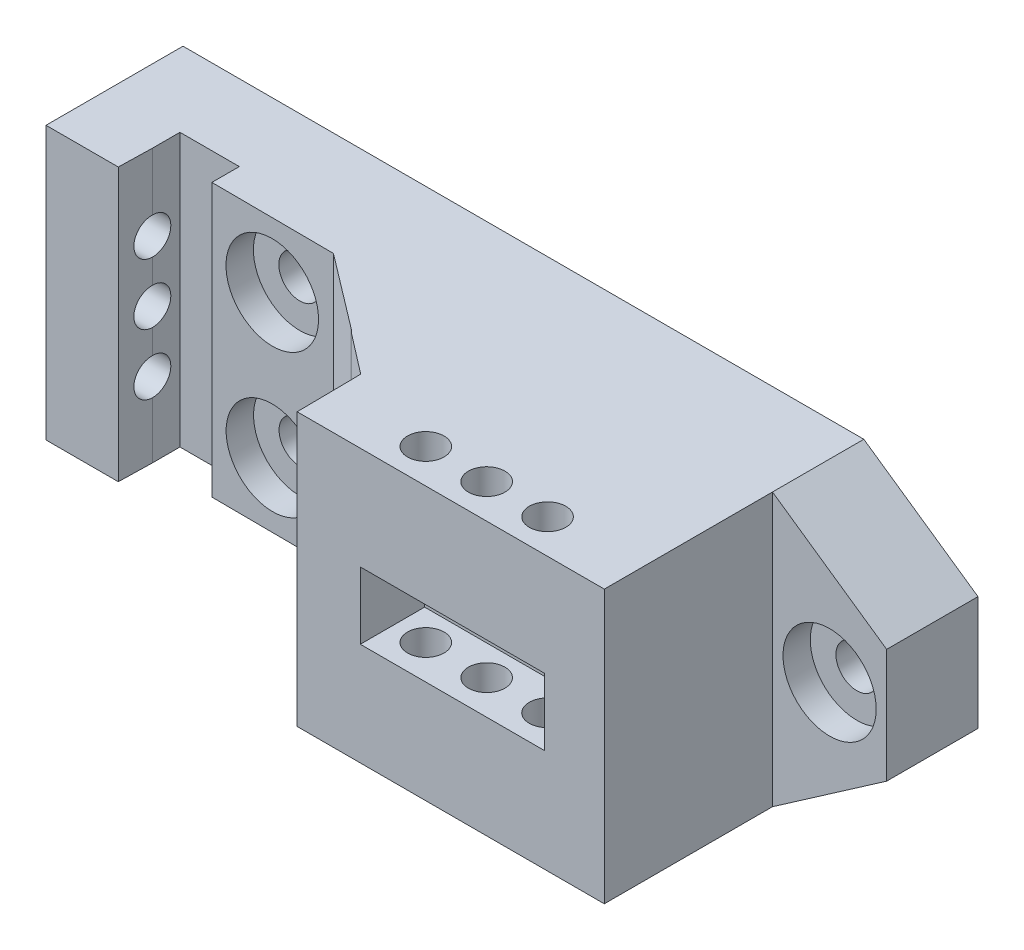
from build123d import *

# Parameters (mm, degrees)
SKETCH2_R                               = 2.4
BOSS_EXTRUDE1_DEPTH                     = 35.814
CUT_EXTRUDE1_DEPTH                      = 8.45076
CBORE_FOR_M5_HEX_HEAD_BOLT1_D           = 5.5
CBORE_FOR_M5_HEX_HEAD_BOLT1_CBORE_D     = 12.24
CBORE_FOR_M5_HEX_HEAD_BOLT1_CBORE_DEPTH = 3.58
BOSS_EXTRUDE2_DEPTH                     = 12
CBORE_FOR_M5_HEX_HEAD_BOLT2_D           = 5.5
CBORE_FOR_M5_HEX_HEAD_BOLT2_DEPTH       = 12
CBORE_FOR_M5_HEX_HEAD_BOLT2_CBORE_D     = 12.24
CBORE_FOR_M5_HEX_HEAD_BOLT2_CBORE_DEPTH = 3.58
CUT_EXTRUDE2_REACH                      = 106.459
SKETCH11_R                              = 2.4


with BuildPart() as part:
    # Sketch2 → Boss-Extrude1 (new body)
    with BuildSketch(Plane(origin=(0, 0, 0), x_dir=(1, 0, 0), z_dir=(0, 1, 0))):
        Polygon((79.858578644, 45.6), (79.858578644, 11.5), (39.5, 11.5), (39.4, 19.95075985), (34.265987805, 23.9), (33.603154542, 24.5), (23.866312437, 31.9), (7.8, 32), (7.8, 35.6), (0, 35.6), (0, 32), (-0.1, 27.6), (-9.6, 27.6), (-9.6, 45.6), align=None)
        with Locations((67.9, 16)):
            Circle(SKETCH2_R, mode=Mode.SUBTRACT)
        with Locations((51.9, 16)):
            Circle(SKETCH2_R, mode=Mode.SUBTRACT)
        with Locations((59.9, 16)):
            Circle(SKETCH2_R, mode=Mode.SUBTRACT)
    extrude(amount=BOSS_EXTRUDE1_DEPTH)

    # Sketch4 → Cut-Extrude1 (cut)
    with BuildSketch(Plane.XY.offset(-11.5)):
        Polygon((67.9, 22.307), (51.9, 22.307), (47.8, 22.307), (47.8, 13.507), (51.9, 13.507), (67.9, 13.507), (72, 13.507), (72, 22.307), align=None)
    extrude(amount=-CUT_EXTRUDE1_DEPTH, mode=Mode.SUBTRACT)

    # CBORE for M5 Hex Head Bolt1 (through all)
    with Locations(Plane(origin=(0.199468966, 0, -32.047307253), x_dir=(0.99998063, 0, 0.006224083), z_dir=(-0.006224083, 0, 0.99998063))):
        with Locations((15.578271559, 27.314), (15.600678258, 8.5)):
            CounterBoreHole(CBORE_FOR_M5_HEX_HEAD_BOLT1_D / 2, CBORE_FOR_M5_HEX_HEAD_BOLT1_CBORE_D / 2, CBORE_FOR_M5_HEX_HEAD_BOLT1_CBORE_DEPTH)

    # Sketch8 → Boss-Extrude2 (add)
    with BuildSketch(Plane(origin=(0, 0, -45.6), x_dir=(-1, 0, 0), z_dir=(0, 0, -1))):
        Polygon((-79.858578644, 35.814), (-94.858578644, 25.407), (-94.858578644, 10.407), (-79.858578644, 0), align=None)
    extrude(amount=-BOSS_EXTRUDE2_DEPTH)

    # CBORE for M5 Hex Head Bolt2
    with Locations(Plane.XY.offset(-33.6)):
        with Locations((87.358578644, 17.907)):
            CounterBoreHole(CBORE_FOR_M5_HEX_HEAD_BOLT2_D / 2, CBORE_FOR_M5_HEX_HEAD_BOLT2_CBORE_D / 2, CBORE_FOR_M5_HEX_HEAD_BOLT2_CBORE_DEPTH, depth=CBORE_FOR_M5_HEX_HEAD_BOLT2_DEPTH)

    # Sketch11 → Cut-Extrude2 (cut, up to next)
    with BuildSketch(Plane.ZY.offset(9.6), mode=Mode.PRIVATE) as cut_extrude2_sk1:
        with Locations((-32, 25.814)):
            Circle(SKETCH11_R)
    cut_extrude2_tool1 = extrude(cut_extrude2_sk1.sketch, amount=-CUT_EXTRUDE2_REACH, mode=Mode.PRIVATE) & part.part
    add(cut_extrude2_tool1.solids().sort_by_distance((-9.6, 25.814, -32))[0], mode=Mode.SUBTRACT)
    # Sketch11 → Cut-Extrude2 (cut, up to next)
    with BuildSketch(Plane.ZY.offset(9.6), mode=Mode.PRIVATE) as cut_extrude2_sk2:
        with Locations((-32, 17.814)):
            Circle(SKETCH11_R)
    cut_extrude2_tool2 = extrude(cut_extrude2_sk2.sketch, amount=-CUT_EXTRUDE2_REACH, mode=Mode.PRIVATE) & part.part
    add(cut_extrude2_tool2.solids().sort_by_distance((-9.6, 17.814, -32))[0], mode=Mode.SUBTRACT)
    # Sketch11 → Cut-Extrude2 (cut, up to next)
    with BuildSketch(Plane.ZY.offset(9.6), mode=Mode.PRIVATE) as cut_extrude2_sk3:
        with Locations((-32, 9.814)):
            Circle(SKETCH11_R)
    cut_extrude2_tool3 = extrude(cut_extrude2_sk3.sketch, amount=-CUT_EXTRUDE2_REACH, mode=Mode.PRIVATE) & part.part
    add(cut_extrude2_tool3.solids().sort_by_distance((-9.6, 9.814, -32))[0], mode=Mode.SUBTRACT)


solid = part.part
